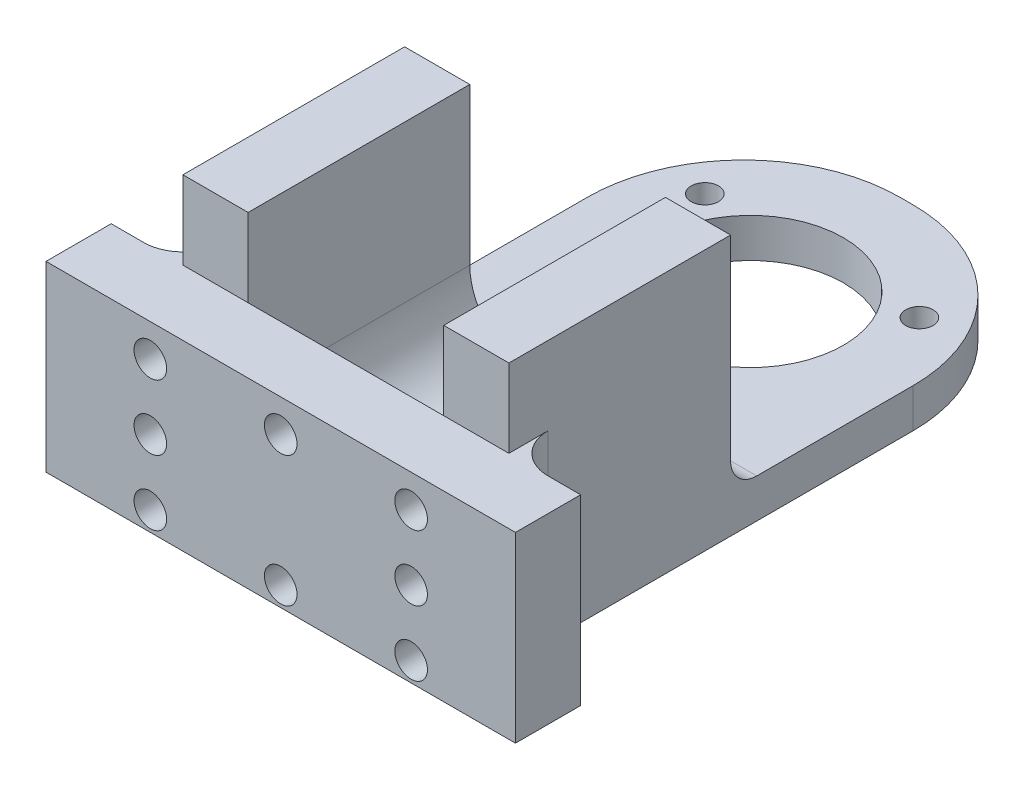
from build123d import *

# Parameters (mm, degrees)
SKETCH1_W            = 25
SKETCH1_H            = 20
MAIN_DEPTH           = 43
SKETCH5_R            = 1.05
SKETCH5_R_2          = 7.15
MAINANDFIXHOLE_DEPTH = 21
SKETCH6_R            = 2.2
CODERFIXHOLE2_DEPTH  = 1.5
SKETCH7_W            = 26
SKETCH7_H            = 17
CODERHOLE_DEPTH      = 26
SKETCH10_W           = 36
SKETCH10_H           = 14
LINK_DEPTH           = 5
SKETCH8_R            = 1.25
VERTICALHOLES_DEPTH  = 10
SKETCH9_W            = 15
SKETCH9_H            = 17
CUT_EXTRUDE6_DEPTH   = 17
FILLET2_R            = 2
FILLET3_R            = 5
FILLET4_R            = 3
FILLET5_R            = 12


with BuildPart() as part:
    # Sketch1 → Main (new body)
    with BuildSketch(Plane.XY):
        Rectangle(SKETCH1_W, SKETCH1_H)
    extrude(amount=MAIN_DEPTH)

    # Sketch5 → MainAndFixHole (cut, through all)
    with BuildSketch(Plane(origin=(0, -10, 0), x_dir=(-1, 0, 0), z_dir=(0, -1, 0))):
        with Locations((0, -21.5)):
            Circle(SKETCH5_R)
        with Locations((-8.227241336, -7.25)):
            Circle(SKETCH5_R)
        with Locations((8.227241336, -7.25)):
            Circle(SKETCH5_R)
        with Locations((0, -12)):
            Circle(SKETCH5_R_2)
    extrude(amount=-MAINANDFIXHOLE_DEPTH, mode=Mode.SUBTRACT)

    # Sketch6 → CoderFixHole2 (cut)
    with BuildSketch(Plane(origin=(0, -10, 0), x_dir=(-1, 0, 0), z_dir=(0, -1, 0))):
        with Locations((0, -21.5)):
            Circle(SKETCH6_R)
        with Locations((-8.227241336, -7.25)):
            Circle(SKETCH6_R)
        with Locations((8.227241336, -7.25)):
            Circle(SKETCH6_R)
    extrude(amount=-CODERFIXHOLE2_DEPTH, mode=Mode.SUBTRACT)

    # Sketch7 → CoderHole (cut, through all)
    with BuildSketch(Plane(origin=(12.5, 0, 0), x_dir=(0, 0, -1), z_dir=(1, 0, 0))):
        with Locations((-13, 1.5)):
            Rectangle(SKETCH7_W, SKETCH7_H)
    extrude(amount=-CODERHOLE_DEPTH, mode=Mode.SUBTRACT)

    # Sketch10 → Link (add)
    with BuildSketch(Plane.XY.offset(43)):
        with Locations((0, -3)):
            Rectangle(SKETCH10_W, SKETCH10_H)
    extrude(amount=LINK_DEPTH)

    # Sketch8 → VerticalHoles (cut)
    with BuildSketch(Plane.XY.offset(48)):
        with Locations((-10, 1.5)):
            Circle(SKETCH8_R)
        with Locations((-10, -8.5)):
            Circle(SKETCH8_R)
        with Locations((10, -8.5)):
            Circle(SKETCH8_R)
        with Locations((10, 1.5)):
            Circle(SKETCH8_R)
        with Locations((-10, -3.5)):
            Circle(SKETCH8_R)
        with Locations((10, -3.5)):
            Circle(SKETCH8_R)
        with Locations((0, 1.5)):
            Circle(SKETCH8_R)
        with Locations((0, -8.5)):
            Circle(SKETCH8_R)
    extrude(amount=-VERTICALHOLES_DEPTH, mode=Mode.SUBTRACT)

    # Sketch9 → Cut-Extrude6 (cut)
    with BuildSketch(Plane(origin=(0, 10, 0), x_dir=(1, 0, 0), z_dir=(0, 1, 0))):
        with Locations((0, -34.5)):
            Rectangle(SKETCH9_W, SKETCH9_H)
    extrude(amount=-CUT_EXTRUDE6_DEPTH, mode=Mode.SUBTRACT)

    # Fillet2
    fillet2_edges = [part.edges().sort_by_distance(p)[0] for p in [
        (10, -7, 26),
        (-10, -7, 26),
    ]]
    fillet(fillet2_edges, radius=FILLET2_R)

    # Fillet3
    fillet3_edges = [part.edges().sort_by_distance(p)[0] for p in [
        (-7.5, -7, 34.5),
        (7.5, -7, 34.5),
    ]]
    fillet(fillet3_edges, radius=FILLET3_R)

    # Fillet4
    fillet4_edges = [part.edges().sort_by_distance(p)[0] for p in [
        (12.5, -3, 43),
        (-12.5, -3, 43),
    ]]
    fillet(fillet4_edges, radius=FILLET4_R)

    # Fillet5
    fillet5_edges = [part.edges().sort_by_distance(p)[0] for p in [
        (-12.5, -8.5, 0),
        (12.5, -8.5, 0),
    ]]
    fillet(fillet5_edges, radius=FILLET5_R)


solid = part.part
